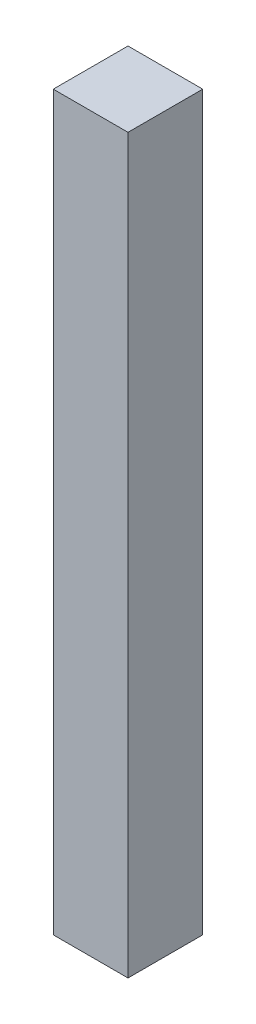
from build123d import *

# Parameters (mm, degrees)
ESQUISSE1_W        = 100
ESQUISSE1_H        = 980
BOSS_EXTRU_1_DEPTH = 100


with BuildPart() as part:
    # Esquisse1 → Boss.-Extru.1 (new body)
    with BuildSketch(Plane.XY):
        Rectangle(ESQUISSE1_W, ESQUISSE1_H)
    extrude(amount=BOSS_EXTRU_1_DEPTH)


solid = part.part
